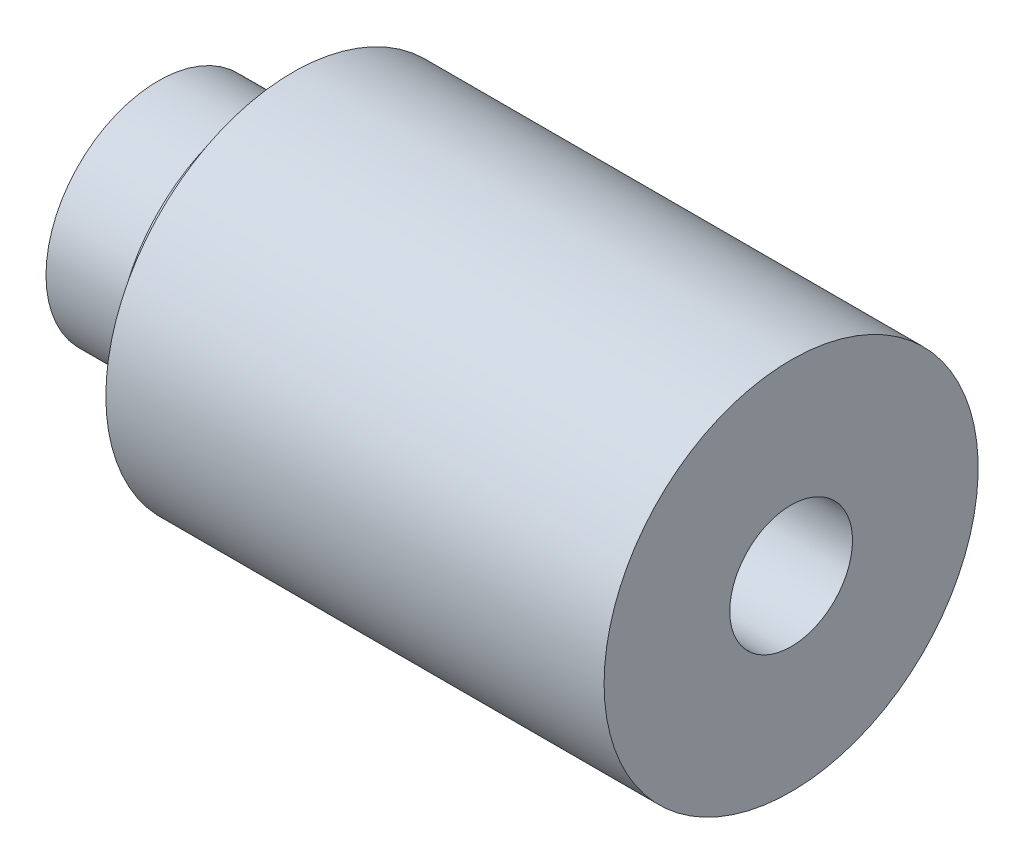
from build123d import *

# Parameters (mm, degrees)
HOLE_WIZARD_8_2_8_2_1_D = 8.2


with BuildPart() as part:
    # Эскиз1 → Повернуть1 (revolve)
    with BuildSketch(Plane.XY):
        Polygon((1.2, 0), (1.2, 7.5), (8.2, 7.5), (8.2, 9.833333333), (10.2, 9.833333333), (10.2, 12.5), (43.5, 12.5), (43.5, 0), align=None)
    revolve(axis=Axis((-1000, 0, 0), (1, 0, 0)))

    # Диаметр отверстия Ø8.2 (8.2)1 (through all)
    with Locations(Plane.ZY.offset(-1.2)):
        with Locations((0, 0)):
            Hole(HOLE_WIZARD_8_2_8_2_1_D / 2)


solid = part.part
